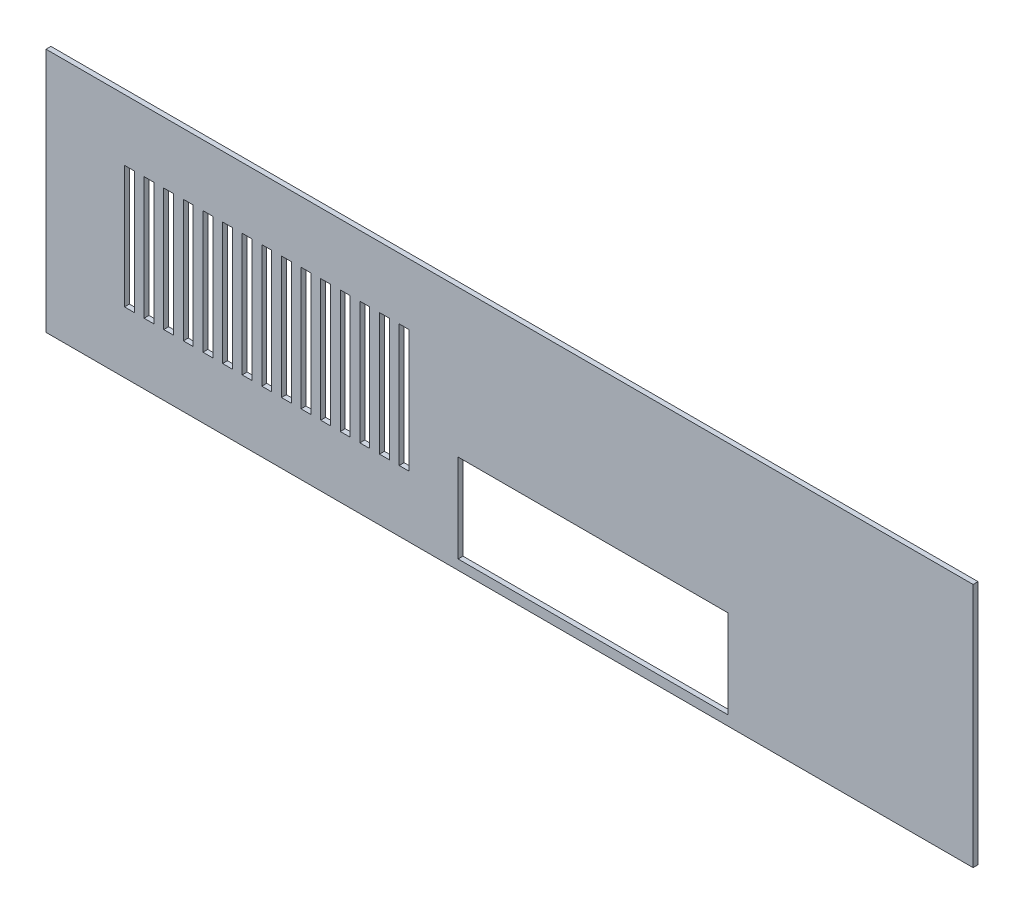
from build123d import *

# Parameters (mm, degrees)
SKETCH1_W           = 189
SKETCH1_H           = 50
BOSS_EXTRUDE1_DEPTH = 1
SKETCH2_W           = 55
SKETCH2_H           = 18
CUT_EXTRUDE1_DEPTH  = 2
SKETCH3_W           = 2
SKETCH3_H           = 25
CUT_EXTRUDE2_DEPTH  = 2


with BuildPart() as part:
    # Sketch1 → Boss-Extrude1 (new body)
    with BuildSketch(Plane.XY):
        with Locations((32.8655586, 16.198012015)):
            Rectangle(SKETCH1_W, SKETCH1_H)
    extrude(amount=BOSS_EXTRUDE1_DEPTH)

    # Sketch2 → Cut-Extrude1 (cut, through all)
    with BuildSketch(Plane.XY.offset(1)):
        with Locations((49.8655586, 2.198012015)):
            Rectangle(SKETCH2_W, SKETCH2_H)
    extrude(amount=-CUT_EXTRUDE1_DEPTH, mode=Mode.SUBTRACT)

    # Sketch3 → Cut-Extrude2 (cut, through all)
    with BuildSketch(Plane(origin=(0, 0, 0), x_dir=(-1, 0, 0), z_dir=(0, 0, -1))):
        with Locations((-11.3655586, 16.198012015)):
            Rectangle(SKETCH3_W, SKETCH3_H)
        with Locations((-7.3655586, 16.198012015)):
            Rectangle(SKETCH3_W, SKETCH3_H)
        with Locations((-3.3655586, 16.198012015)):
            Rectangle(SKETCH3_W, SKETCH3_H)
        with Locations((0.6344414, 16.198012015)):
            Rectangle(SKETCH3_W, SKETCH3_H)
        with Locations((4.6344414, 16.198012015)):
            Rectangle(SKETCH3_W, SKETCH3_H)
        with Locations((8.6344414, 16.198012015)):
            Rectangle(SKETCH3_W, SKETCH3_H)
        with Locations((12.6344414, 16.198012015)):
            Rectangle(SKETCH3_W, SKETCH3_H)
        with Locations((16.6344414, 16.198012015)):
            Rectangle(SKETCH3_W, SKETCH3_H)
        with Locations((20.6344414, 16.198012015)):
            Rectangle(SKETCH3_W, SKETCH3_H)
        with Locations((24.6344414, 16.198012015)):
            Rectangle(SKETCH3_W, SKETCH3_H)
        with Locations((28.6344414, 16.198012015)):
            Rectangle(SKETCH3_W, SKETCH3_H)
        with Locations((32.6344414, 16.198012015)):
            Rectangle(SKETCH3_W, SKETCH3_H)
        with Locations((36.6344414, 16.198012015)):
            Rectangle(SKETCH3_W, SKETCH3_H)
        with Locations((40.6344414, 16.198012015)):
            Rectangle(SKETCH3_W, SKETCH3_H)
        with Locations((44.6344414, 16.198012015)):
            Rectangle(SKETCH3_W, SKETCH3_H)
    extrude(amount=-CUT_EXTRUDE2_DEPTH, mode=Mode.SUBTRACT)


solid = part.part
